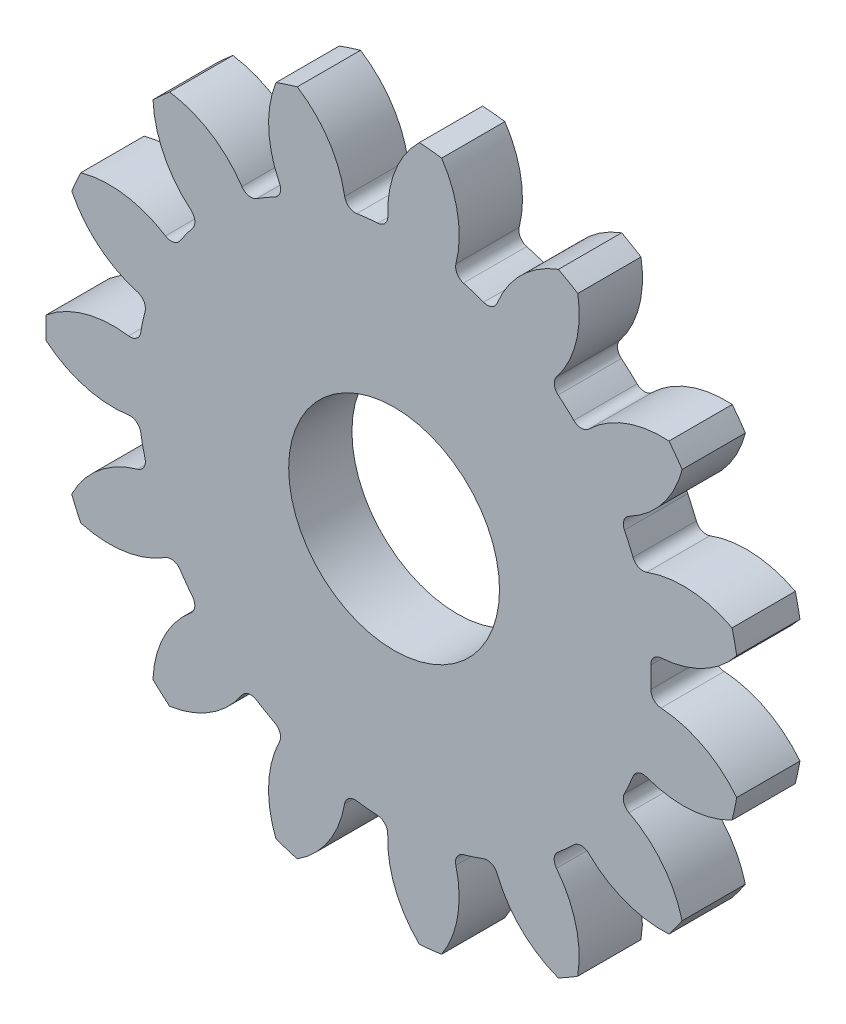
from build123d import *

# Parameters (mm, degrees)
CROQUIS1_R              = 16.51
SALIENTE_EXTRUIR1_DEPTH = 3
CORTAR_EXTRUIR1_DEPTH   = 4
REDONDEO1_R             = 0.508
MATRIZC1_COUNT          = 15
REDONDEO1_OF_MATRIZC1_R = 0.508
CROQUIS3_R              = 5
CORTAR_EXTRUIR2_DEPTH   = 4.0000001


with BuildPart() as part:
    # Croquis1 → Saliente-Extruir1 (new body)
    with BuildSketch(Plane.XY):
        Circle(CROQUIS1_R)
    extrude(amount=SALIENTE_EXTRUIR1_DEPTH)

    # Croquis2 → Cortar-Extruir1 (cut, through all)
    with BuildSketch(Plane.XY.offset(3)):
        with BuildLine():
            ThreePointArc((1.19987849, 16.466341173), (-1.722782609, 16.419869673), (-4.591442554, 15.858712283))
            ThreePointArc((-4.591442554, 15.858712283), (-2.974123566, 14.192987656), (-2.28451161, 11.976054054))
            ThreePointArc((-2.28451161, 11.976054054), (-1.272208696, 12.12544222), (-0.250944175, 12.189417173))
            ThreePointArc((-0.250944175, 12.189417173), (-0.036488513, 14.501206093), (1.19987849, 16.466341173))
        make_face()
    cortar_extruir1 = extrude(amount=-CORTAR_EXTRUIR1_DEPTH, mode=Mode.SUBTRACT)

    # Redondeo1
    redondeo1_edges = [part.edges().sort_by_distance(p)[0] for p in [
        (-0.250944175, 12.189417173, 1.5),
        (-2.28451161, 11.976054054, 1.5),
    ]]
    fillet(redondeo1_edges, radius=REDONDEO1_R)

    # MatrizC1: Cortar-Extruir1 ×15 about axis
    matrizc1_axis = Axis((0, 0, 0), (0, 0, 1))
    for i in range(1, MATRIZC1_COUNT):
        add(cortar_extruir1.rotate(matrizc1_axis, i * 360 / MATRIZC1_COUNT), mode=Mode.SUBTRACT)

    # Redondeo1 of MatrizC1
    redondeo1_of_matrizc1_edges = [part.edges().sort_by_distance(p)[0] for p in [
        (-5.187131533, 11.033518498, 1.5),
        (-6.958105228, 10.011475198, 1.5),
        (-9.226416726, 7.969824239, 1.5),
        (-10.428579239, 6.315821329, 1.5),
        (-11.670370647, 3.528074965, 1.5),
        (-12.095857159, 1.528104575, 1.5),
        (-12.096411461, -1.523710522, 1.5),
        (-11.671651489, -3.523835343, 1.5),
        (-10.430872842, -6.312032617, 1.5),
        (-9.229311243, -7.966472117, 1.5),
        (-6.961741546, -10.00894693, 1.5),
        (-5.191139237, -11.031633488, 1.5),
        (-2.288861892, -11.97522339, 1.5),
        (-0.255372097, -12.189325211, 1.5),
        (2.779782777, -11.870874934, 1.5),
        (4.724551198, -11.239371867, 1.5),
        (7.367777751, -9.713944359, 1.5),
        (8.88755667, -8.346029022, 1.5),
        (10.681817017, -5.877384556, 1.5),
        (11.513822853, -4.009581937, 1.5),
        (12.148873079, -1.024571569, 1.5),
        (12.149244465, 1.02015829, 1.5),
        (11.515278618, 4.005399151, 1.5),
        (10.683951336, 5.873503882, 1.5),
        (8.89058787, 8.342799969, 1.5),
        (7.371305961, 9.711267293, 1.5),
        (4.728633711, 11.237654881, 1.5),
        (2.784094819, 11.869864365, 1.5),
    ]]
    fillet(redondeo1_of_matrizc1_edges, radius=REDONDEO1_OF_MATRIZC1_R)

    # Croquis3 → Cortar-Extruir2 (cut, through all)
    with BuildSketch(Plane.XY.offset(3)):
        Circle(CROQUIS3_R)
    extrude(amount=-CORTAR_EXTRUIR2_DEPTH, mode=Mode.SUBTRACT)


solid = part.part
